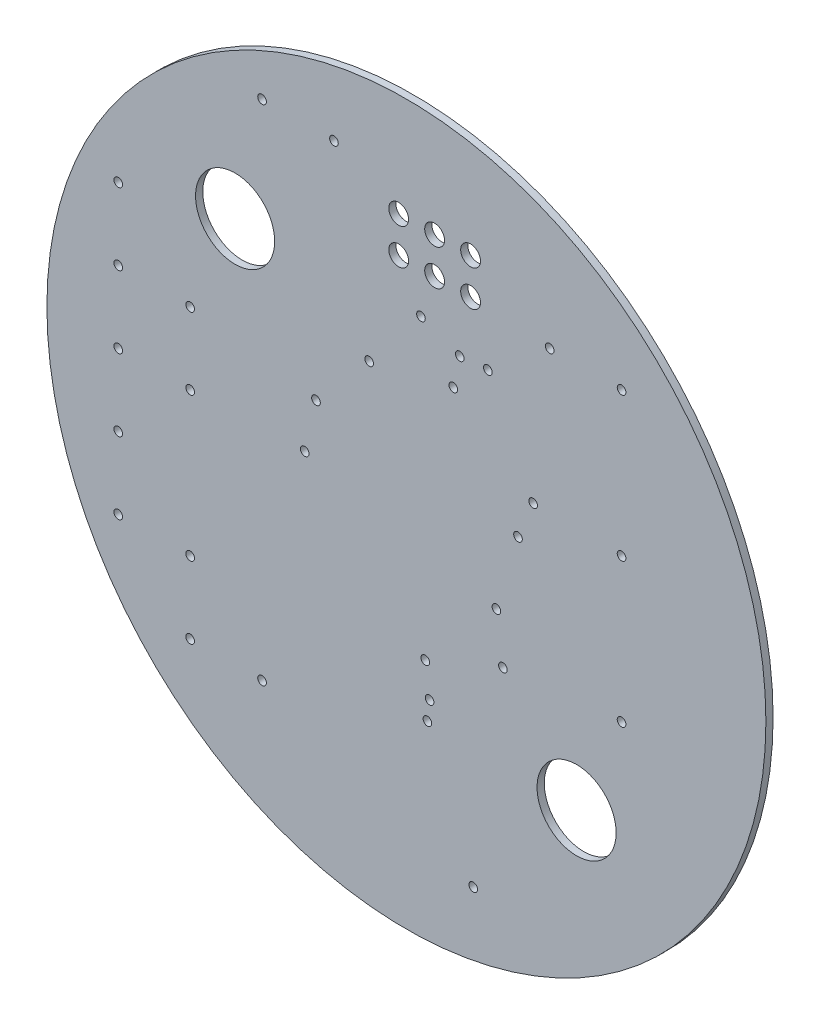
from build123d import *

# Parameters (mm, degrees)
BOARD_OUTLINE_START = 0.034
BOARD_OUTLINE_DEPTH = 0.254
SKETCH2_R           = 0.1525
VIA_DEPTH           = 1.288
SKETCH3_R           = 1.397
NPTH_DEPTH          = 1.288
SKETCH4_R           = 0.35
SKETCH4_R_2         = 0.1525
PTH_DEPTH           = 1.288


with BuildPart() as part:
    # Sketch1 → Board_Outline (new body)
    with BuildSketch(Plane.XY.offset(BOARD_OUTLINE_START)):
        with BuildLine():
            ThreePointArc((-8.961, -8.961), (9, -8.961), (9, 9))
            ThreePointArc((9, 9), (-8.961, 9), (-8.961, -8.961))
        make_face()
    extrude(amount=BOARD_OUTLINE_DEPTH)

    # Sketch2 → Via (cut, through all)
    with BuildSketch(Plane.XY):
        with Locations((-1.295, 4.039)):
            Circle(SKETCH2_R)
        with Locations((-3.572, 0.144)):
            Circle(SKETCH2_R)
        with Locations((0.533, 6.325)):
            Circle(SKETCH2_R)
        with Locations((2.896, 5.867)):
            Circle(SKETCH2_R)
        with Locations((1.676, 4.724)):
            Circle(SKETCH2_R)
        with Locations((0.686, -4.115)):
            Circle(SKETCH2_R)
        with Locations((0.838, -5.258)):
            Circle(SKETCH2_R)
        with Locations((0.762, -5.944)):
            Circle(SKETCH2_R)
        with Locations((3.2, -1.295)):
            Circle(SKETCH2_R)
        with Locations((4.496, 2.591)):
            Circle(SKETCH2_R)
        with Locations((3.962, 1.295)):
            Circle(SKETCH2_R)
        with Locations((2.381, -10.211)):
            Circle(SKETCH2_R)
        with Locations((3.429, -2.972)):
            Circle(SKETCH2_R)
        with Locations((1.905, 5.791)):
            Circle(SKETCH2_R)
        with Locations((-3.175, 1.905)):
            Circle(SKETCH2_R)
    extrude(amount=VIA_DEPTH, mode=Mode.SUBTRACT)

    # Sketch3 → NPTH (cut, through all)
    with BuildSketch(Plane.XY):
        with Locations((6.032, -6.032)):
            Circle(SKETCH3_R)
        with Locations((-6.032, 6.032)):
            Circle(SKETCH3_R)
    extrude(amount=NPTH_DEPTH, mode=Mode.SUBTRACT)

    # Sketch4 → PTH (cut, through all)
    with BuildSketch(Plane.XY):
        with Locations((2.286, 9.068)):
            Circle(SKETCH4_R)
        with Locations((1.016, 9.068)):
            Circle(SKETCH4_R)
        with Locations((-0.254, 9.068)):
            Circle(SKETCH4_R)
        with Locations((2.286, 7.798)):
            Circle(SKETCH4_R)
        with Locations((1.016, 7.798)):
            Circle(SKETCH4_R)
        with Locations((-0.254, 7.798)):
            Circle(SKETCH4_R)
        with Locations((-7.62, 2.54)):
            Circle(SKETCH4_R_2)
        with Locations((-7.62, 0)):
            Circle(SKETCH4_R_2)
        with Locations((-10.16, 5.08)):
            Circle(SKETCH4_R_2)
        with Locations((7.62, -2.54)):
            Circle(SKETCH4_R_2)
        with Locations((5.08, 7.62)):
            Circle(SKETCH4_R_2)
        with Locations((-7.62, -7.62)):
            Circle(SKETCH4_R_2)
        with Locations((-5.08, -7.62)):
            Circle(SKETCH4_R_2)
        with Locations((-7.62, -5.08)):
            Circle(SKETCH4_R_2)
        with Locations((-10.16, -2.54)):
            Circle(SKETCH4_R_2)
        with Locations((-10.16, 0)):
            Circle(SKETCH4_R_2)
        with Locations((-10.16, 2.54)):
            Circle(SKETCH4_R_2)
        with Locations((7.62, 2.54)):
            Circle(SKETCH4_R_2)
        with Locations((7.62, 7.62)):
            Circle(SKETCH4_R_2)
        with Locations((-10.16, -5.08)):
            Circle(SKETCH4_R_2)
        with Locations((-5.08, 10.16)):
            Circle(SKETCH4_R_2)
        with Locations((-2.54, 10.16)):
            Circle(SKETCH4_R_2)
    extrude(amount=PTH_DEPTH, mode=Mode.SUBTRACT)


solid = part.part
